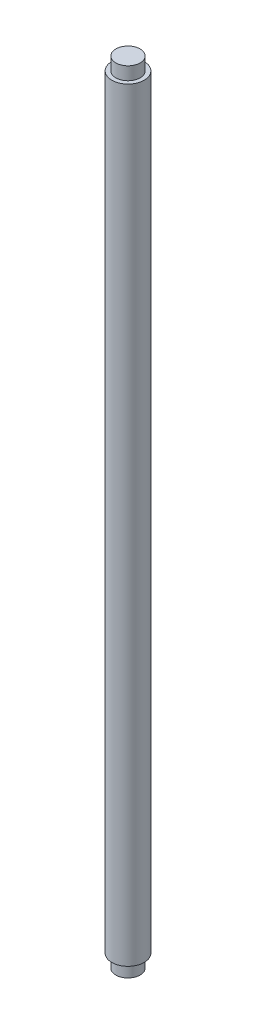
from build123d import *

# Parameters (mm, degrees)
CROQUIS1_R              = 2.5
SALIENTE_EXTRUIR1_DEPTH = 118
CROQUIS2_R              = 1.875
SALIENTE_EXTRUIR2_DEPTH = 2
CROQUIS3_R              = 1.875
SALIENTE_EXTRUIR3_DEPTH = 2


with BuildPart() as part:
    # Croquis1 → Saliente-Extruir1 (new body)
    with BuildSketch(Plane(origin=(0, 0, 0), x_dir=(1, 0, 0), z_dir=(0, 1, 0))):
        Circle(CROQUIS1_R)
    extrude(amount=SALIENTE_EXTRUIR1_DEPTH)

    # Croquis2 → Saliente-Extruir2 (add)
    with BuildSketch(Plane(origin=(0, 118, 0), x_dir=(1, 0, 0), z_dir=(0, 1, 0))):
        Circle(CROQUIS2_R)
    extrude(amount=SALIENTE_EXTRUIR2_DEPTH)

    # Croquis3 → Saliente-Extruir3 (add)
    with BuildSketch(Plane.XZ):
        Circle(CROQUIS3_R)
    extrude(amount=SALIENTE_EXTRUIR3_DEPTH)


solid = part.part
